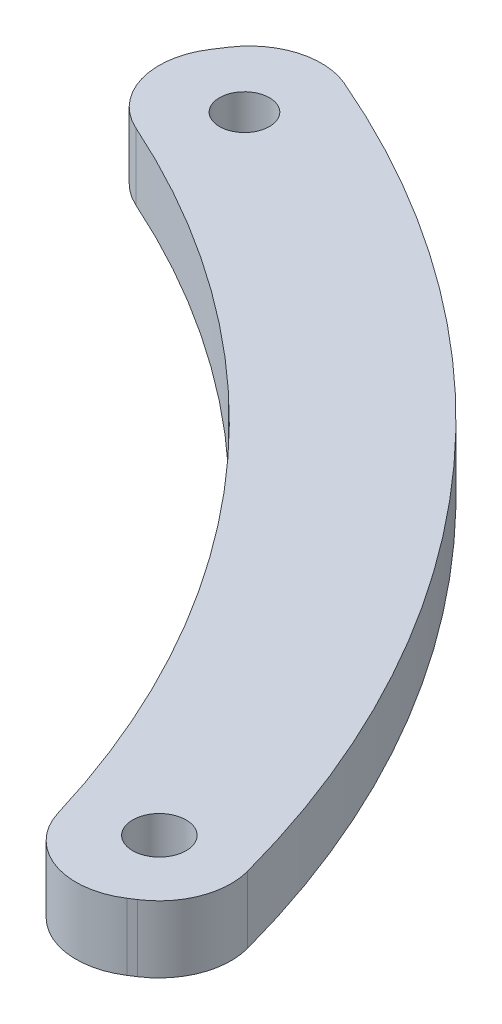
from build123d import *

# Parameters (mm, degrees)
SCHIZZO1_R                   = 0.936245514
SCHIZZO1_R_2                 = 1
ESTRUSIONE_ESTRUSIONE1_DEPTH = 2.5
RACCORDO1_R                  = 2.7


with BuildPart() as part:
    # Schizzo1 → Estrusione-Estrusione1 (new body)
    with BuildSketch(Plane(origin=(0, 0, 0), x_dir=(1, 0, 0), z_dir=(0, 1, 0))):
        with BuildLine():
            Line((0, 0), (5.035291563, 3.262796174))
            ThreePointArc((5.035291563, 3.262796174), (-4.27091895, 21.690860387), (-21.285586763, 33.382745778))
            Line((-21.285586763, 33.382745778), (-24.592109016, 28.376059189))
            ThreePointArc((-24.592109016, 28.376059189), (-8.523142058, 17.457823812), (0, 0))
        make_face()
        with Locations((-20.099209332, 29.73535462)):
            Circle(SCHIZZO1_R, mode=Mode.SUBTRACT)
        with Locations((1.745777445, 4.706006726)):
            Circle(SCHIZZO1_R_2, mode=Mode.SUBTRACT)
    extrude(amount=ESTRUSIONE_ESTRUSIONE1_DEPTH)

    # Raccordo1
    raccordo1_edges = [part.edges().sort_by_distance(p)[0] for p in [
        (-24.592109016, 1.25, -28.376059189),
        (-21.285586763, 1.25, -33.382745778),
        (5.035291563, 1.25, -3.262796174),
        (0, 1.25, 0),
    ]]
    fillet(raccordo1_edges, radius=RACCORDO1_R)


solid = part.part
